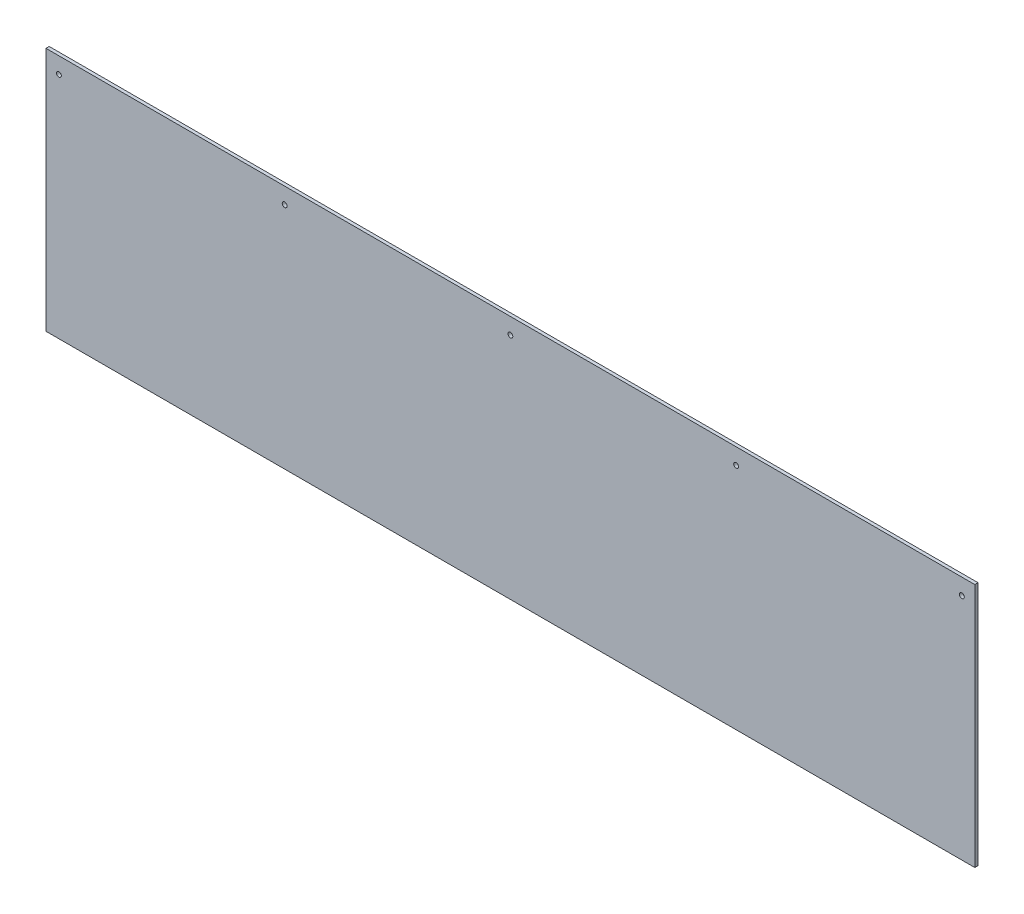
from build123d import *

# Parameters (mm, degrees)
SKETCH1_W           = 1828.8
SKETCH1_H           = 482.6
BOSS_EXTRUDE1_DEPTH = 6.35
SKETCH2_R           = 4.7625
CUT_EXTRUDE1_DEPTH  = 7.35


with BuildPart() as part:
    # Sketch1 → Boss-Extrude1 (new body)
    with BuildSketch(Plane.XY):
        with Locations((914.4, 241.3)):
            Rectangle(SKETCH1_W, SKETCH1_H)
    extrude(amount=BOSS_EXTRUDE1_DEPTH)

    # Sketch2 → Cut-Extrude1 (cut, through all)
    with BuildSketch(Plane.XY.offset(6.35)):
        with Locations((25.4, 450.85)):
            Circle(SKETCH2_R)
        with Locations((469.9, 450.85)):
            Circle(SKETCH2_R)
        with Locations((914.4, 450.85)):
            Circle(SKETCH2_R)
        with Locations((1358.9, 450.85)):
            Circle(SKETCH2_R)
        with Locations((1803.4, 450.85)):
            Circle(SKETCH2_R)
    extrude(amount=-CUT_EXTRUDE1_DEPTH, mode=Mode.SUBTRACT)


solid = part.part
